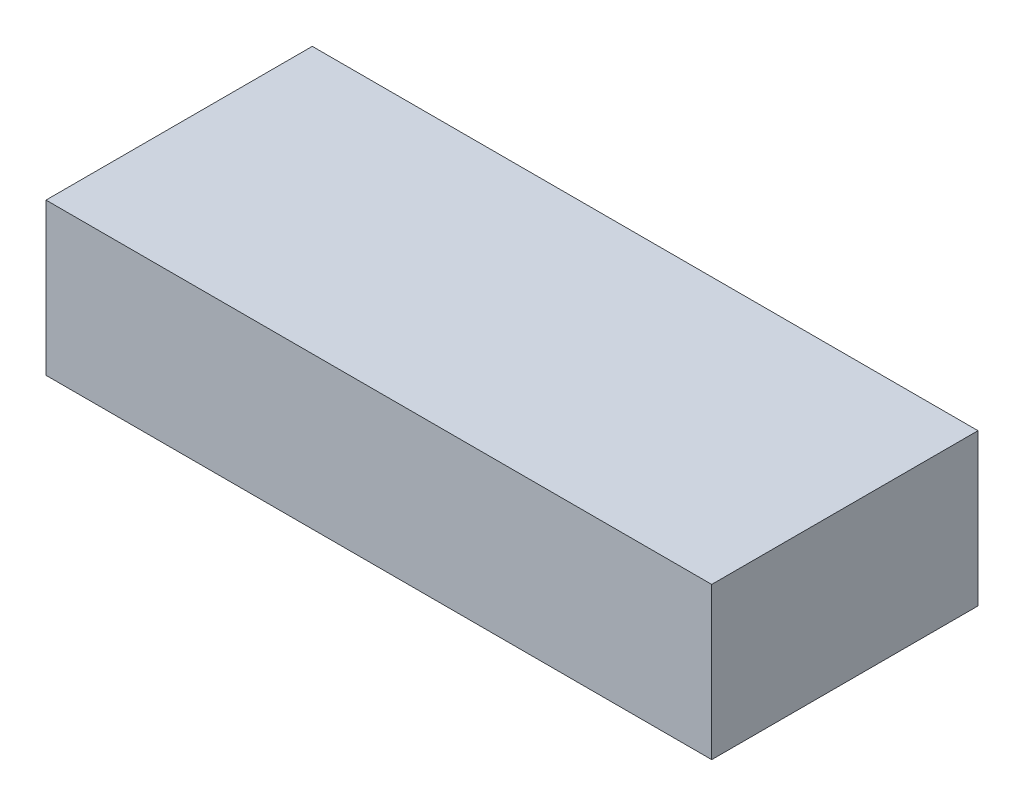
from build123d import *

# Parameters (mm, degrees)
SKETCH1_W           = 25
SKETCH1_H           = 10
BOSS_EXTRUDE1_DEPTH = 5.7


with BuildPart() as part:
    # Sketch1 → Boss-Extrude1 (new body)
    with BuildSketch(Plane(origin=(0, 0, 0), x_dir=(1, 0, 0), z_dir=(0, 1, 0))):
        Rectangle(SKETCH1_W, SKETCH1_H)
    extrude(amount=BOSS_EXTRUDE1_DEPTH)


solid = part.part
